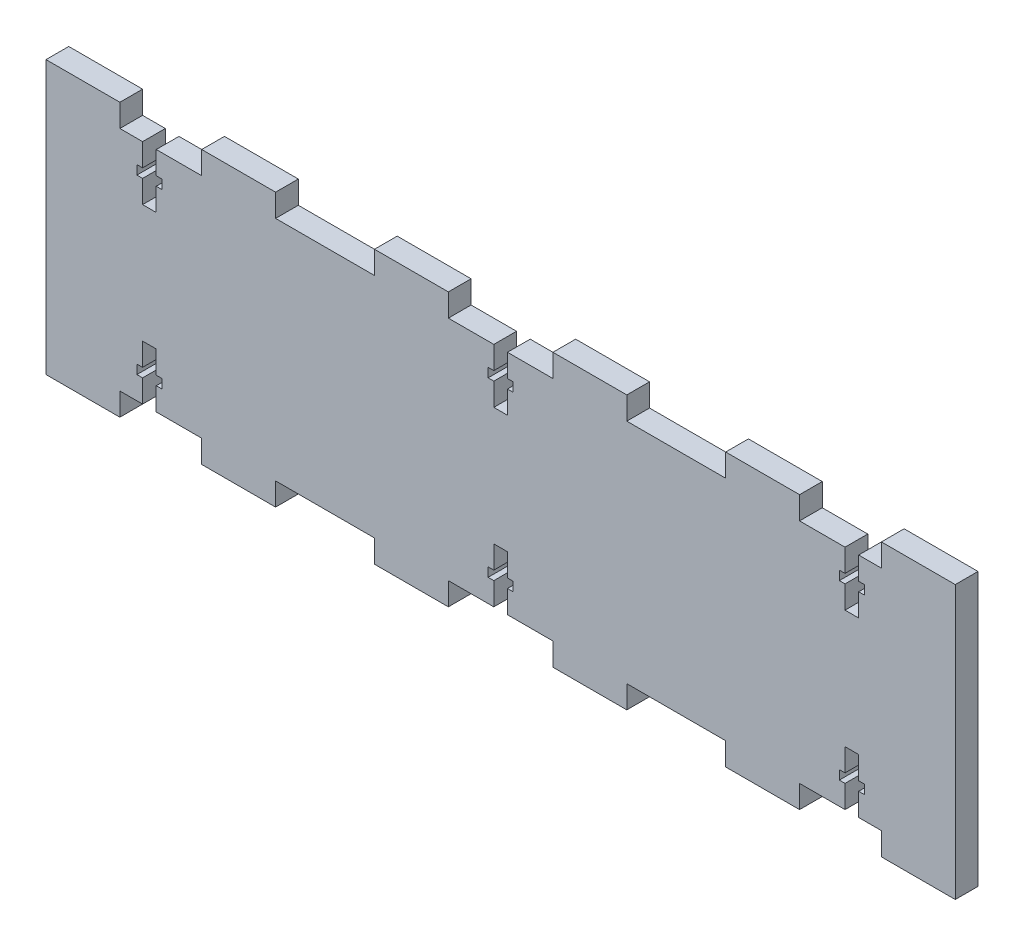
from build123d import *

# Parameters (mm, degrees)
SKETCH1_W           = 200
SKETCH1_H           = 50
BOSS_EXTRUDE1_DEPTH = 5
SKETCH2_W           = 5.5
SKETCH2_H           = 2
SKETCH2_W_2         = 3
SKETCH2_H_2         = 12
CUT_EXTRUDE1_DEPTH  = 5
SKETCH3_W           = 16.25
SKETCH3_H           = 5
BOSS_EXTRUDE2_DEPTH = 5


with BuildPart() as part:
    # Sketch1 → Boss-Extrude1 (new body)
    with BuildSketch(Plane.XY):
        Rectangle(SKETCH1_W, SKETCH1_H)
    extrude(amount=BOSS_EXTRUDE1_DEPTH)

    # Sketch2 → Cut-Extrude1 (cut)
    with BuildSketch(Plane.XY.offset(5)):
        with Locations((-77.25, -19)):
            Rectangle(SKETCH2_W, SKETCH2_H)
        with Locations((-77.25, -19)):
            Rectangle(SKETCH2_W_2, SKETCH2_H_2)
        with Locations((0, -19)):
            Rectangle(SKETCH2_W, SKETCH2_H)
        with Locations((0, -19)):
            Rectangle(SKETCH2_W_2, SKETCH2_H_2)
        with Locations((77.25, -19)):
            Rectangle(SKETCH2_W, SKETCH2_H)
        with Locations((77.25, -19)):
            Rectangle(SKETCH2_W_2, SKETCH2_H_2)
    cut_extrude1 = extrude(amount=-CUT_EXTRUDE1_DEPTH, mode=Mode.SUBTRACT)

    # Sketch3 → Boss-Extrude2 (add)
    with BuildSketch(Plane.XY.offset(5)):
        with Locations((-91.875, -27.5)):
            Rectangle(SKETCH3_W, SKETCH3_H)
        with Locations((-19.625, -27.5)):
            Rectangle(SKETCH3_W, SKETCH3_H)
        with Locations((19.625, -27.5)):
            Rectangle(SKETCH3_W, SKETCH3_H)
        with Locations((57.625, -27.5)):
            Rectangle(SKETCH3_W, SKETCH3_H)
        with Locations((91.875, -27.5)):
            Rectangle(SKETCH3_W, SKETCH3_H)
        with Locations((-57.625, -27.5)):
            Rectangle(SKETCH3_W, SKETCH3_H)
    boss_extrude2 = extrude(amount=-BOSS_EXTRUDE2_DEPTH)

    # Mirror1: Cut-Extrude1, Boss-Extrude2 across plane
    add(cut_extrude1.mirror(Plane.ZX), mode=Mode.SUBTRACT)
    add(boss_extrude2.mirror(Plane.ZX))


solid = part.part
